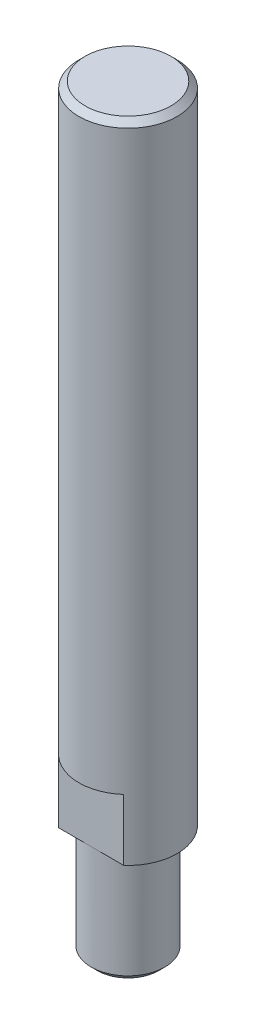
from build123d import *

# Parameters (mm, degrees)
ESBO_O1_R                = 8
RESSALTO_EXTRUS_O1_DEPTH = 105
ESBO_O2_R                = 6
RESSALTO_EXTRUS_O2_DEPTH = 18
CHANFRO1_SIZE            = 1
ESBO_O3_OUTSIDE_W        = 43.012
ESBO_O3_OUTSIDE_H        = 43.012
CORTE_EXTRUS_O1_DEPTH    = 10


with BuildPart() as part:
    # Esboço1 → Ressalto-extrusão1 (new body)
    with BuildSketch(Plane(origin=(0, 0, 0), x_dir=(1, 0, 0), z_dir=(0, 1, 0))):
        with Locations(Location((0, 0, 0), (0, 0, 270))):  # turned: the seam where the file's is
            Circle(ESBO_O1_R)
    extrude(amount=RESSALTO_EXTRUS_O1_DEPTH)

    # Esboço2 → Ressalto-extrusão2 (add)
    with BuildSketch(Plane.XZ):
        with Locations(Location((0, 0, 0), (0, 0, 270))):  # turned: the seam where the file's is
            Circle(ESBO_O2_R)
    extrude(amount=RESSALTO_EXTRUS_O2_DEPTH)

    # Chanfro1
    chanfro1_edges = [part.edges().sort_by_distance(p)[0] for p in [
        (0, 105, -8),
        (0, -18, 6),
    ]]
    chamfer(chanfro1_edges, length=CHANFRO1_SIZE)

    # Esboço3 outside → Corte-extrusão1 (cut)
    with BuildSketch(Plane.XZ):
        Rectangle(ESBO_O3_OUTSIDE_W, ESBO_O3_OUTSIDE_H)
        with BuildLine():
            Line((-8, 6), (8, 6))
            ThreePointArc((8, 6), (14, 0), (8, -6))
            Line((8, -6), (-8, -6))
            ThreePointArc((-8, -6), (-14, 0), (-8, 6))
        make_face(mode=Mode.SUBTRACT)
    extrude(amount=-CORTE_EXTRUS_O1_DEPTH, mode=Mode.SUBTRACT)


solid = part.part
